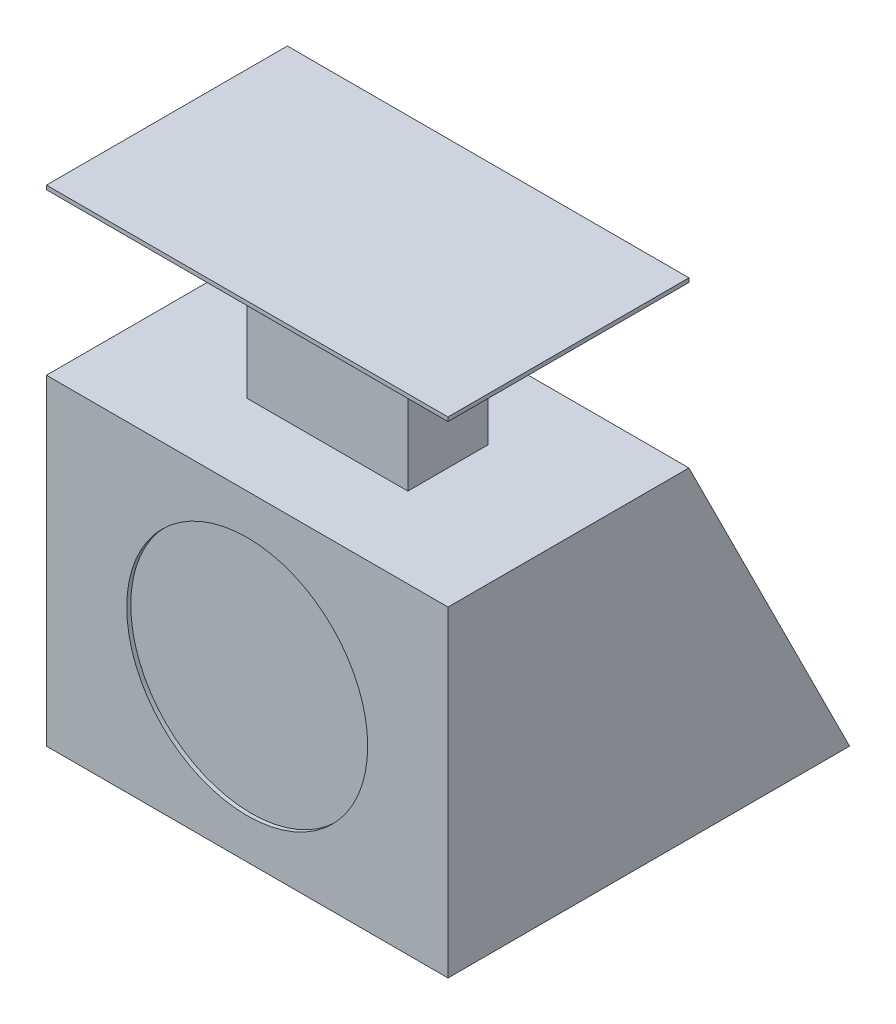
from build123d import *

# Parameters (mm, degrees)
EXTRUDE1_DEPTH     = 100
SKETCH2_R          = 30
CUT_EXTRUDE1_DEPTH = 1
SKETCH3_W          = 40
SKETCH3_H          = 20
EXTRUDE2_DEPTH     = 40
SKETCH4_W          = 100
SKETCH4_H          = 60
EXTRUDE3_DEPTH     = 1


with BuildPart() as part:
    # Sketch1 → Extrude1 (new body)
    with BuildSketch(Plane(origin=(0, 0, 0), x_dir=(0, 0, -1), z_dir=(1, 0, 0))):
        Polygon((100, 0), (0, 0), (0, 80), (60, 80), align=None)
    extrude(amount=EXTRUDE1_DEPTH)

    # Sketch2 → Cut-Extrude1 (cut)
    with BuildSketch(Plane.XY):
        with Locations((50, 40)):
            Circle(SKETCH2_R)
    extrude(amount=-CUT_EXTRUDE1_DEPTH, mode=Mode.SUBTRACT)

    # Sketch3 → Extrude2 (add)
    with BuildSketch(Plane(origin=(0, 80, 0), x_dir=(-1, 0, 0), z_dir=(0, 1, 0))):
        with Locations((-50, -30)):
            Rectangle(SKETCH3_W, SKETCH3_H)
    extrude(amount=EXTRUDE2_DEPTH)

    # Sketch4 → Extrude3 (add)
    with BuildSketch(Plane(origin=(0, 120, 0), x_dir=(-1, 0, 0), z_dir=(0, 1, 0))):
        with Locations((-50, -30)):
            Rectangle(SKETCH4_W, SKETCH4_H)
    extrude(amount=EXTRUDE3_DEPTH)


solid = part.part
